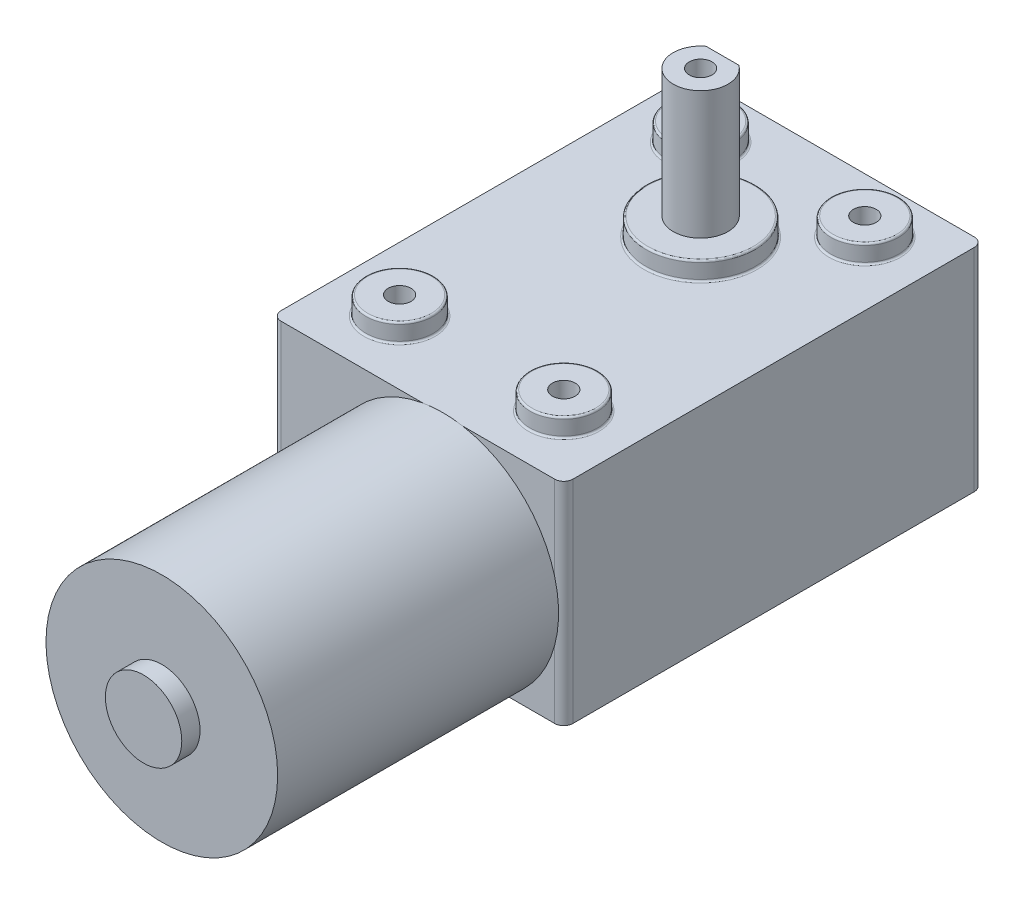
from build123d import *

# Parameters (mm, degrees)
SKETCH1_W                 = 32
SKETCH1_H                 = 46
BOSS_EXTRUDE1_DEPTH       = 23.2
SKETCH2_R                 = 3.7
SKETCH2_R_2               = 6
BOSS_EXTRUDE2_DEPTH       = 2
SKETCH8_R                 = 3
BOSS_EXTRUDE3_DEPTH       = 14
M3X0_5_TAPPED_HOLE2_D     = 2.5
M3X0_5_TAPPED_HOLE2_DEPTH = 12
M3X0_5_TAPPED_HOLE2_TIP   = 0.751075774
CUT_EXTRUDE1_DEPTH        = 12
M3X0_5_TAPPED_HOLE1_D     = 2.5
M3X0_5_TAPPED_HOLE1_DEPTH = 7.5
M3X0_5_TAPPED_HOLE1_TIP   = 0.751075774
FILLET1_R                 = 1
FILLET2_R                 = 0.2
SKETCH11_R                = 12.7
BOSS_EXTRUDE4_DEPTH       = 30.8
SKETCH17_R                = 4.189113183
BOSS_EXTRUDE5_DEPTH       = 2


with BuildPart() as part:
    # Sketch1 → Boss-Extrude1 (new body)
    with BuildSketch(Plane(origin=(0, 0, 0), x_dir=(1, 0, 0), z_dir=(0, 1, 0))):
        with Locations((16, 23)):
            Rectangle(SKETCH1_W, SKETCH1_H)
    extrude(amount=BOSS_EXTRUDE1_DEPTH)

    # Sketch2 → Boss-Extrude2 (add)
    with BuildSketch(Plane(origin=(0, 23.2, 0), x_dir=(1, 0, 0), z_dir=(0, 1, 0))):
        with Locations((7, 40)):
            Circle(SKETCH2_R)
        with Locations((25, 40)):
            Circle(SKETCH2_R)
        with Locations((7, 7)):
            Circle(SKETCH2_R)
        with Locations((25, 7)):
            Circle(SKETCH2_R)
        with Locations((16, 31)):
            Circle(SKETCH2_R_2)
    extrude(amount=BOSS_EXTRUDE2_DEPTH)

    # Sketch8 → Boss-Extrude3 (add)
    with BuildSketch(Plane(origin=(0, 25.2, 0), x_dir=(1, 0, 0), z_dir=(0, 1, 0))):
        with Locations((16, 31)):
            Circle(SKETCH8_R)
    extrude(amount=BOSS_EXTRUDE3_DEPTH)

    # M3x0.5 Tapped Hole2
    with Locations(Plane(origin=(0, 39.2, 0), x_dir=(1, 0, 0), z_dir=(0, 1, 0))):
        with Locations((16, 31)):
            Hole(M3X0_5_TAPPED_HOLE2_D / 2, depth=M3X0_5_TAPPED_HOLE2_DEPTH)
            with Locations((0, 0, -(M3X0_5_TAPPED_HOLE2_DEPTH + M3X0_5_TAPPED_HOLE2_TIP / 2))):  # 118° drill point
                Cone(0, M3X0_5_TAPPED_HOLE2_D / 2, M3X0_5_TAPPED_HOLE2_TIP, mode=Mode.SUBTRACT)

    # Sketch9 → Cut-Extrude1 (cut)
    with BuildSketch(Plane(origin=(0, 39.2, 0), x_dir=(1, 0, 0), z_dir=(0, 1, 0))):
        with BuildLine():
            Line((14.2, 33.4), (17.8, 33.4))
            ThreePointArc((17.8, 33.4), (16, 34), (14.2, 33.4))
        make_face()
    extrude(amount=-CUT_EXTRUDE1_DEPTH, mode=Mode.SUBTRACT)

    # M3x0.5 Tapped Hole1
    with Locations(Plane(origin=(0, 25.2, 0), x_dir=(1, 0, 0), z_dir=(0, 1, 0))):
        with Locations((25, 7), (7, 7), (7, 40), (25, 40)):
            Hole(M3X0_5_TAPPED_HOLE1_D / 2, depth=M3X0_5_TAPPED_HOLE1_DEPTH)
            with Locations((0, 0, -(M3X0_5_TAPPED_HOLE1_DEPTH + M3X0_5_TAPPED_HOLE1_TIP / 2))):  # 118° drill point
                Cone(0, M3X0_5_TAPPED_HOLE1_D / 2, M3X0_5_TAPPED_HOLE1_TIP, mode=Mode.SUBTRACT)

    # Fillet1
    fillet1_edges = [part.edges().sort_by_distance(p)[0] for p in [
        (0, 11.6, -46),
        (32, 11.6, -46),
        (32, 11.6, 0),
        (0, 11.6, 0),
    ]]
    fillet(fillet1_edges, radius=FILLET1_R)

    # Fillet2
    fillet2_edges = [part.edges().sort_by_distance(p)[0] for p in [
        (3.3, 23.2, -40),
        (3.3, 25.2, -40),
        (21.3, 23.2, -40),
        (21.3, 25.2, -40),
        (3.3, 23.2, -7),
        (3.3, 25.2, -7),
        (21.3, 23.2, -7),
        (21.3, 25.2, -7),
        (10, 23.2, -31),
        (10, 25.2, -31),
    ]]
    fillet(fillet2_edges, radius=FILLET2_R)

    # Sketch11 → Boss-Extrude4 (add)
    with BuildSketch(Plane(origin=(-0.758996234, 0, 0), x_dir=(1, 0, 0), z_dir=(0, 0, 1))):
        with Locations((19.48879467, 10.688193303)):
            Circle(SKETCH11_R)
    extrude(amount=BOSS_EXTRUDE4_DEPTH)

    # Sketch17 → Boss-Extrude5 (add)
    with BuildSketch(Plane(origin=(-0.758996234, 0, 30.8), x_dir=(1, 0, 0), z_dir=(0, 0, 1))):
        with Locations((19.48879467, 10.688193303)):
            Circle(SKETCH17_R)
    extrude(amount=BOSS_EXTRUDE5_DEPTH)


solid = part.part
